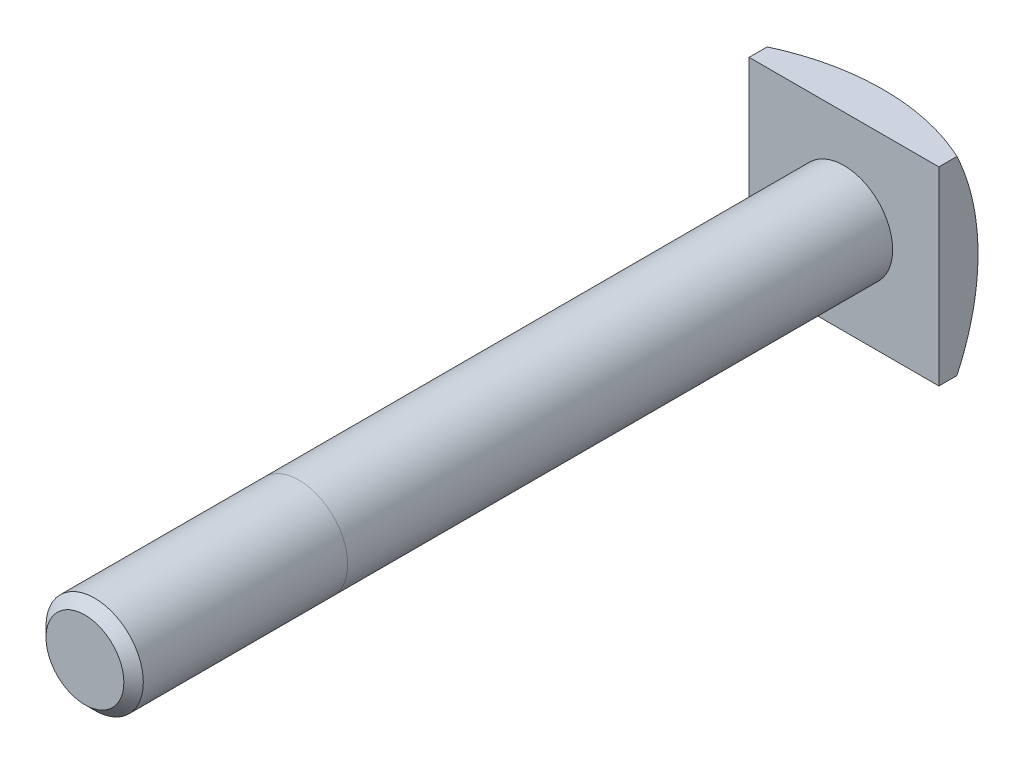
from build123d import *

# Parameters (mm, degrees)
SKETCH2_W           = 19.5
SKETCH2_H           = 19.5
BOSS_EXTRUDE1_DEPTH = 6
SKETCH3_R           = 5
BOSS_EXTRUDE2_DEPTH = 78
CHAMFER1_SIZE       = 1


with BuildPart() as part:
    # Sketch2 → Boss-Extrude1 (new body)
    with BuildSketch(Plane.XY):
        Rectangle(SKETCH2_W, SKETCH2_H)
    extrude(amount=BOSS_EXTRUDE1_DEPTH)

    # Sketch3 → Boss-Extrude2 (add)
    with BuildSketch(Plane.XY.offset(6)):
        Circle(SKETCH3_R)
    extrude(amount=BOSS_EXTRUDE2_DEPTH)

    # Chamfer1
    chamfer1_edges = [part.edges().sort_by_distance(p)[0] for p in [
        (-5, 0, 84),
    ]]
    chamfer(chamfer1_edges, length=CHAMFER1_SIZE)

    # Sketch4 → Cut-Revolve1 (revolve, cut)
    with BuildSketch(Plane(origin=(0, 0, 0), x_dir=(1, 0, 0), z_dir=(0, 1, 0))):
        with BuildLine():
            Line((0, 8.673011737), (0, 0))
            ThreePointArc((0, 0), (17.67766953, -7.32233047), (25, -25))
            Line((25, -25), (33.673011737, -25))
            ThreePointArc((33.673011737, -25), (23.810414942, -1.189585058), (0, 8.673011737))
        make_face()
    revolve(axis=Axis((0, 0, 0), (0, 0, 1)), mode=Mode.SUBTRACT)


solid = part.part
